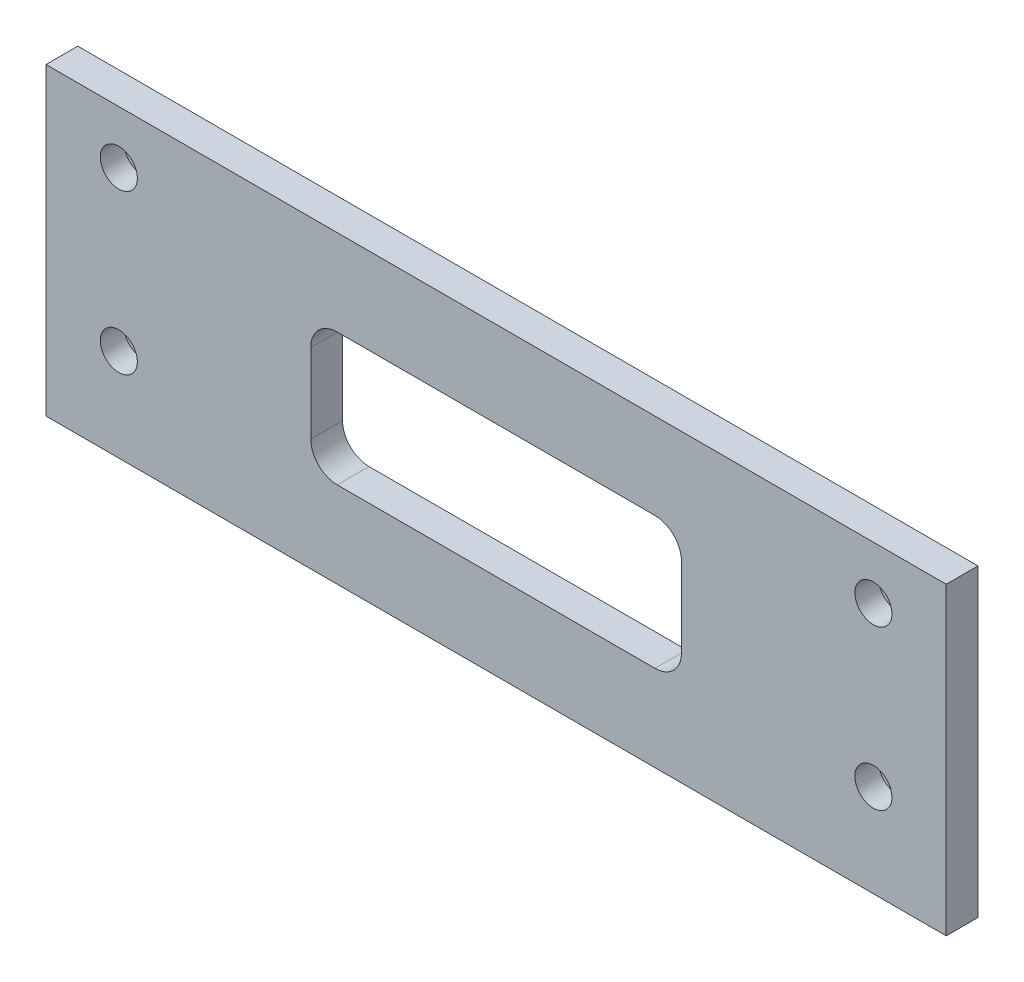
from build123d import *

# Parameters (mm, degrees)
SKETCH_1_W                = 340
SKETCH_1_H                = 115
EXTRUDE_1_DEPTH           = 12
HOLE_WIZARD_1_D           = 9
HOLE_WIZARD_1_CBORE_D     = 14
HOLE_WIZARD_1_CBORE_DEPTH = 9
CUT_EXTRUDE_1_DEPTH       = 13


with BuildPart() as part:
    # 草图1 → 凸台-拉伸1 (new body)
    with BuildSketch(Plane.XY):
        Rectangle(SKETCH_1_W, SKETCH_1_H)
    extrude(amount=EXTRUDE_1_DEPTH)

    # 打孔尺寸(%根据)内六角圆柱头螺钉的类型1 (through all)
    with Locations(Plane.XY.offset(12)):
        with Locations((-142.5, 37.5), (142.5, 37.5), (142.5, -22.5), (-142.5, -22.5)):
            CounterBoreHole(HOLE_WIZARD_1_D / 2, HOLE_WIZARD_1_CBORE_D / 2, HOLE_WIZARD_1_CBORE_DEPTH)

    # 草图4 → 切除-拉伸1 (cut, through all)
    with BuildSketch(Plane.XY.offset(12)):
        with BuildLine():
            Line((-60, 25), (60, 25))
            ThreePointArc((60, 25), (67.071067812, 22.071067812), (70, 15))
            Line((70, 15), (70, -15))
            ThreePointArc((70, -15), (67.071067812, -22.071067812), (60, -25))
            Line((60, -25), (-60, -25))
            ThreePointArc((-60, -25), (-67.071067812, -22.071067812), (-70, -15))
            Line((-70, -15), (-70, 15))
            ThreePointArc((-70, 15), (-67.071067812, 22.071067812), (-60, 25))
        make_face()
    extrude(amount=-CUT_EXTRUDE_1_DEPTH, mode=Mode.SUBTRACT)


solid = part.part
